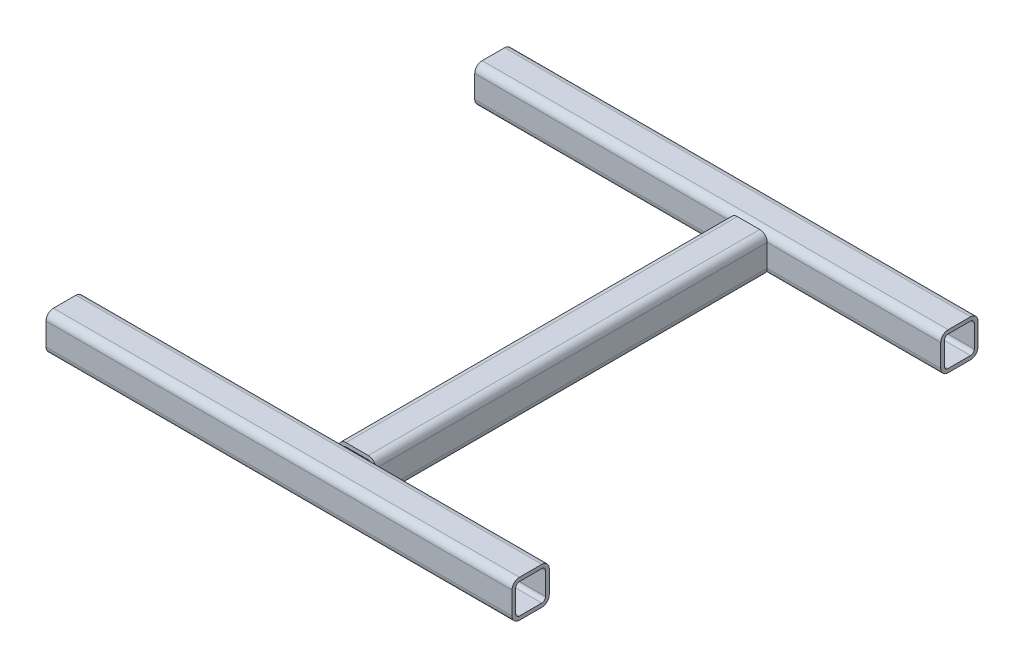
from build123d import *

# Parameters (mm, degrees)
SQUARE_TUBE_40_X_40_X_4_1_DEPTH   = 500
SQUARE_TUBE_40_X_40_X_4_1_2_DEPTH = 500
SQUARE_TUBE_40_X_40_X_4_1_3_DEPTH = 462


with BuildPart() as part:
    # Sketch1 → Square tube 40 X 40 X 4(1) (new body)
    with BuildSketch(Plane(origin=(0, 0, 0), x_dir=(0, 0, -1), z_dir=(1, 0, 0))):
        with BuildLine():
            Line((-12, -20), (12, -20))
            ThreePointArc((12, -20), (17.656854249, -17.656854249), (20, -12))
            Line((20, -12), (20, 12))
            ThreePointArc((20, 12), (17.656854249, 17.656854249), (12, 20))
            Line((12, 20), (-12, 20))
            ThreePointArc((-12, 20), (-17.656854249, 17.656854249), (-20, 12))
            Line((-20, 12), (-20, -12))
            ThreePointArc((-20, -12), (-17.656854249, -17.656854249), (-12, -20))
        make_face()
        with BuildLine():
            Line((-12, -16), (12, -16))
            ThreePointArc((12, -16), (14.828427125, -14.828427125), (16, -12))
            Line((16, -12), (16, 12))
            ThreePointArc((16, 12), (14.828427125, 14.828427125), (12, 16))
            Line((12, 16), (-12, 16))
            ThreePointArc((-12, 16), (-14.828427125, 14.828427125), (-16, 12))
            Line((-16, 12), (-16, -12))
            ThreePointArc((-16, -12), (-14.828427125, -14.828427125), (-12, -16))
        make_face(mode=Mode.SUBTRACT)
    extrude(amount=SQUARE_TUBE_40_X_40_X_4_1_DEPTH)


with BuildPart() as body_2:
    # Sketch1 on segment 2 (carried to segment 2) → Square tube 40 X 40 X 4_1 2 (new body)
    with BuildSketch(Plane(origin=(0, 0, 460), x_dir=(0, 0, -1), z_dir=(1, 0, 0))):
        with BuildLine():
            Line((-12, -20), (12, -20))
            ThreePointArc((12, -20), (17.656854249, -17.656854249), (20, -12))
            Line((20, -12), (20, 12))
            ThreePointArc((20, 12), (17.656854249, 17.656854249), (12, 20))
            Line((12, 20), (-12, 20))
            ThreePointArc((-12, 20), (-17.656854249, 17.656854249), (-20, 12))
            Line((-20, 12), (-20, -12))
            ThreePointArc((-20, -12), (-17.656854249, -17.656854249), (-12, -20))
        make_face()
        with BuildLine():
            Line((-12, -16), (12, -16))
            ThreePointArc((12, -16), (14.828427125, -14.828427125), (16, -12))
            Line((16, -12), (16, 12))
            ThreePointArc((16, 12), (14.828427125, 14.828427125), (12, 16))
            Line((12, 16), (-12, 16))
            ThreePointArc((-12, 16), (-14.828427125, 14.828427125), (-16, 12))
            Line((-16, 12), (-16, -12))
            ThreePointArc((-16, -12), (-14.828427125, -14.828427125), (-12, -16))
        make_face(mode=Mode.SUBTRACT)
    extrude(amount=SQUARE_TUBE_40_X_40_X_4_1_2_DEPTH)


with BuildPart() as body_3:
    # Sketch1 on segment 3 (carried to segment 3) → Square tube 40 X 40 X 4_1 3 (new body)
    with BuildSketch(Plane(origin=(293.819864636, 0, 461), x_dir=(-1, 0, 0), z_dir=(0, 0, -1))):
        with BuildLine():
            Line((-12, -20), (12, -20))
            ThreePointArc((12, -20), (17.656854249, -17.656854249), (20, -12))
            Line((20, -12), (20, 12))
            ThreePointArc((20, 12), (17.656854249, 17.656854249), (12, 20))
            Line((12, 20), (-12, 20))
            ThreePointArc((-12, 20), (-17.656854249, 17.656854249), (-20, 12))
            Line((-20, 12), (-20, -12))
            ThreePointArc((-20, -12), (-17.656854249, -17.656854249), (-12, -20))
        make_face()
        with BuildLine():
            Line((-12, -16), (12, -16))
            ThreePointArc((12, -16), (14.828427125, -14.828427125), (16, -12))
            Line((16, -12), (16, 12))
            ThreePointArc((16, 12), (14.828427125, 14.828427125), (12, 16))
            Line((12, 16), (-12, 16))
            ThreePointArc((-12, 16), (-14.828427125, 14.828427125), (-16, 12))
            Line((-16, 12), (-16, -12))
            ThreePointArc((-16, -12), (-14.828427125, -14.828427125), (-12, -16))
        make_face(mode=Mode.SUBTRACT)
    extrude(amount=SQUARE_TUBE_40_X_40_X_4_1_3_DEPTH)

    # Square tube 40 X 40 X 4_1 3 end butt 1
    split(bisect_by=Plane(origin=(293.819864636, 0, 440), x_dir=(0, 1, 0), z_dir=(0, 0, -1)), keep=Keep.TOP)

    # Square tube 40 X 40 X 4_1 3 end butt 2
    split(bisect_by=Plane(origin=(293.819864636, 0, 20), x_dir=(0, -1, 0), z_dir=(0, 0, 1)), keep=Keep.TOP)


solid = Compound([part.part, body_2.part, body_3.part])
